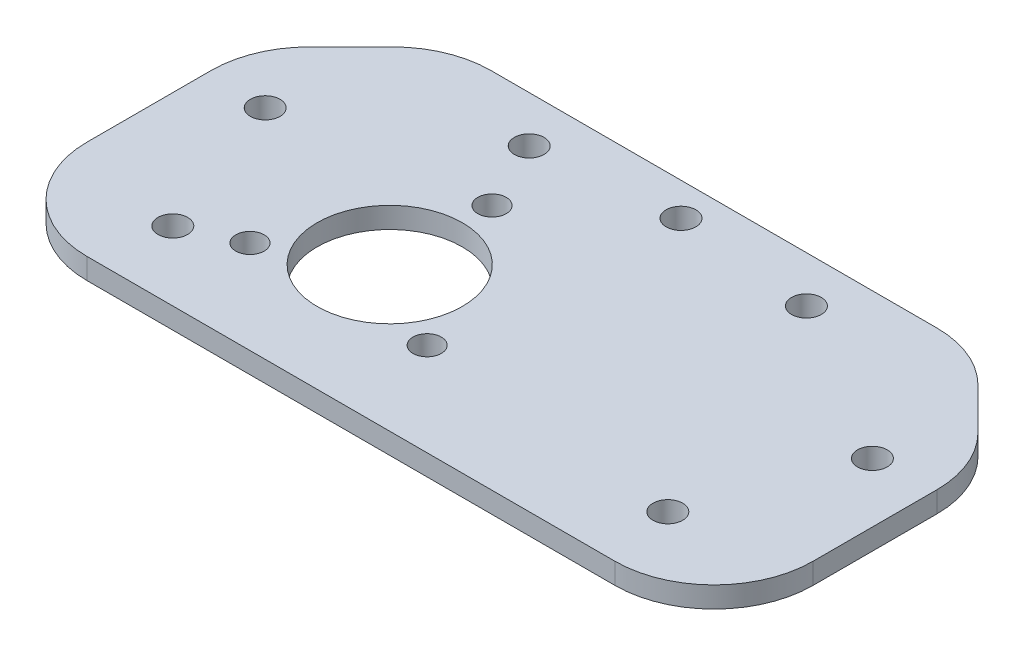
from build123d import *

# Parameters (mm, degrees)
SKETCH2_W                = 110
SKETCH2_H                = 55
BOSS_EXTRUDE1_DEPTH      = 1.5875
M4_CLEARANCE_HOLE1_D     = 4.5
M4_CLEARANCE_HOLE2_D     = 4.5
CHAMFER1_SIZE            = 15
FILLET1_R                = 15
SKETCH8_R                = 11
CUT_EXTRUDE1_DEPTH       = 4.175
M4_CLEARANCE_HOLE3_D     = 4.3
M4_CLEARANCE_HOLE3_DEPTH = 3.175


with BuildPart() as part:
    # Sketch2 → Boss-Extrude1 (new body, symmetric)
    with BuildSketch(Plane(origin=(0, 0, 0), x_dir=(1, 0, 0), z_dir=(0, 1, 0))):
        Rectangle(SKETCH2_W, SKETCH2_H)
    extrude(amount=BOSS_EXTRUDE1_DEPTH, both=True)

    # M4 Clearance Hole1 (through all)
    with Locations(Plane(origin=(0, 1.5875, 0), x_dir=(1, 0, 0), z_dir=(0, 1, 0))):
        with Locations((-46, 5.5), (-21, 20.5), (21, 20.5), (46, 5.5), (0, 22.5)):
            Hole(M4_CLEARANCE_HOLE1_D / 2)

    # M4 Clearance Hole2 (through all)
    with Locations(Plane(origin=(0, -1.5875, 0), x_dir=(-1, 0, 0), z_dir=(0, -1, 0))):
        with Locations((37.5, -17), (-37.5, -17)):
            Hole(M4_CLEARANCE_HOLE2_D / 2)

    # Chamfer1
    chamfer1_edges = [part.edges().sort_by_distance(p)[0] for p in [
        (-55, 0, -27.5),
        (55, 0, -27.5),
    ]]
    chamfer(chamfer1_edges, length=CHAMFER1_SIZE)

    # Fillet1
    fillet1_edges = [part.edges().sort_by_distance(p)[0] for p in [
        (-55, 0, -12.5),
        (40, 0, -27.5),
        (-40, 0, -27.5),
        (55, 0, -12.5),
        (55, 0, 27.5),
        (-55, 0, 27.5),
    ]]
    fillet(fillet1_edges, radius=FILLET1_R)

    # Sketch8 → Cut-Extrude1 (cut, through all)
    with BuildSketch(Plane(origin=(0, -1.5875, 0), x_dir=(-1, 0, 0), z_dir=(0, -1, 0))):
        with Locations((16, -5.635528726)):
            Circle(SKETCH8_R)
    extrude(amount=-CUT_EXTRUDE1_DEPTH, mode=Mode.SUBTRACT)

    # M4 Clearance Hole3
    with Locations(Plane(origin=(0, -1.5875, 0), x_dir=(-1, 0, 0), z_dir=(0, -1, 0))):
        with Locations((16, 9.864471274), (2.576606241, -13.385528726), (29.423393759, -13.385528726)):
            Hole(M4_CLEARANCE_HOLE3_D / 2, depth=M4_CLEARANCE_HOLE3_DEPTH)


solid = part.part
